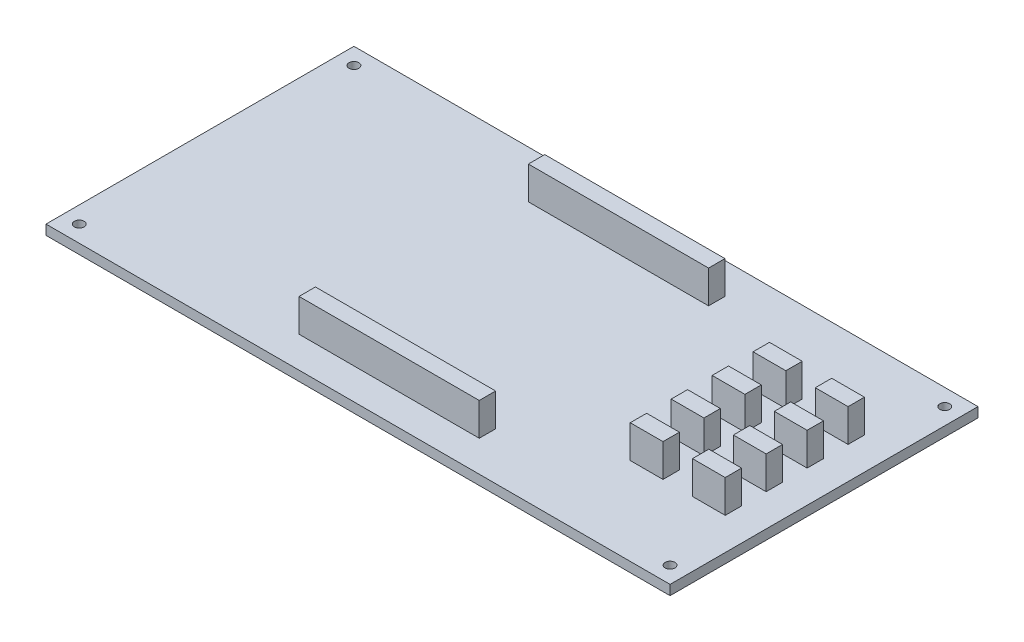
from build123d import *

# Parameters (mm, degrees)
ESQUISSE1_W      = 190.5
ESQUISSE1_H      = 94
ESQUISSE1_R      = 1.5
EXTRUSION1_DEPTH = 3
ESQUISSE2_W      = 55
ESQUISSE2_H      = 5
EXTRUSION2_DEPTH = 10
ESQUISSE4_W      = 10
ESQUISSE4_H      = 5
EXTRUSION4_DEPTH = 10


with BuildPart() as part:
    # Esquisse1 → Extrusion1 (new body)
    with BuildSketch(Plane(origin=(0, 0, 0), x_dir=(1, 0, 0), z_dir=(0, 1, 0))):
        with Locations((95.25, 47)):
            Rectangle(ESQUISSE1_W, ESQUISSE1_H)
        with Locations((5.08, 88.92)):
            Circle(ESQUISSE1_R, mode=Mode.SUBTRACT)
        with Locations((185.42, 88.92)):
            Circle(ESQUISSE1_R, mode=Mode.SUBTRACT)
        with Locations((185.42, 5.08)):
            Circle(ESQUISSE1_R, mode=Mode.SUBTRACT)
        with Locations((5.08, 5.08)):
            Circle(ESQUISSE1_R, mode=Mode.SUBTRACT)
    extrude(amount=EXTRUSION1_DEPTH)

    # Esquisse2 → Extrusion2 (add)
    with BuildSketch(Plane(origin=(0, 3, 0), x_dir=(1, 0, 0), z_dir=(0, 1, 0))):
        with Locations((95.25, 82)):
            Rectangle(ESQUISSE2_W, ESQUISSE2_H)
        with Locations((95.25, 12)):
            Rectangle(ESQUISSE2_W, ESQUISSE2_H)
    extrude(amount=EXTRUSION2_DEPTH)

    # Esquisse4 → Extrusion4 (add)
    with BuildSketch(Plane(origin=(0, 3, 0), x_dir=(1, 0, 0), z_dir=(0, 1, 0))):
        with Locations((175.67625178, 66.658495743)):
            Rectangle(ESQUISSE4_W, ESQUISSE4_H)
        with Locations((156.685730764, 66.658495743)):
            Rectangle(ESQUISSE4_W, ESQUISSE4_H)
        with Locations((156.685730764, 41.658495743)):
            Rectangle(ESQUISSE4_W, ESQUISSE4_H)
        with Locations((156.685730764, 29.158495743)):
            Rectangle(ESQUISSE4_W, ESQUISSE4_H)
        with Locations((156.685730764, 54.158495743)):
            Rectangle(ESQUISSE4_W, ESQUISSE4_H)
        with Locations((175.67625178, 41.658495743)):
            Rectangle(ESQUISSE4_W, ESQUISSE4_H)
        with Locations((175.67625178, 29.158495743)):
            Rectangle(ESQUISSE4_W, ESQUISSE4_H)
        with Locations((175.67625178, 54.158495743)):
            Rectangle(ESQUISSE4_W, ESQUISSE4_H)
    extrude(amount=EXTRUSION4_DEPTH)


solid = part.part
